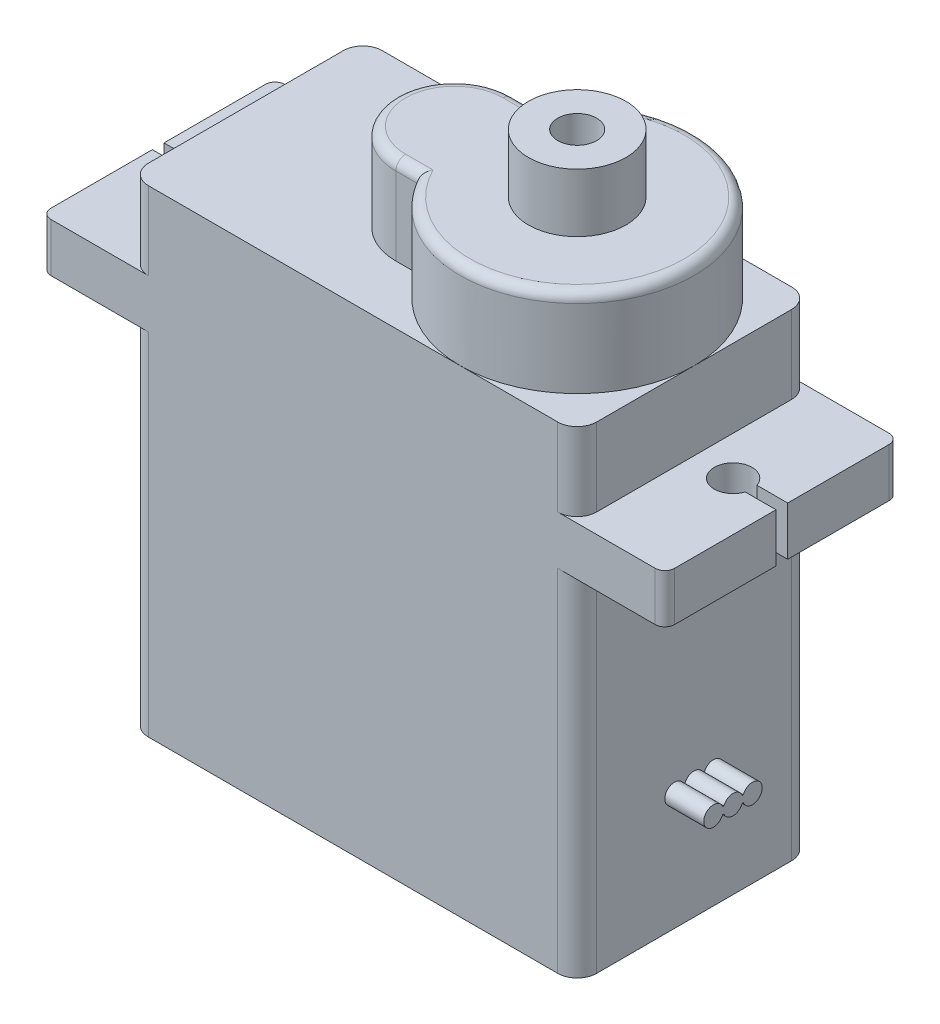
from build123d import *

# Parameters (mm, degrees)
SKETCH1_W            = 23
SKETCH1_H            = 12
BOSS_EXTRUDE1_DEPTH  = 18
SKETCH2_W            = 32
SKETCH2_H            = 12
BOSS_EXTRUDE2_DEPTH  = 2.5
SKETCH3_W            = 23
SKETCH3_H            = 12
BOSS_EXTRUDE3_DEPTH  = 4
BOSS_EXTRUDE4_DEPTH  = 4.5
FILLET1_R            = 1
FILLET2_R            = 0.5
CUT_EXTRUDE2_DEPTH   = 21.5
SKETCH5_R            = 2.5
BOSS_EXTRUDE5_DEPTH  = 3
SKETCH6_R            = 1
CUT_EXTRUDE1_DEPTH   = 3
BOSS_EXTRUDE11_DEPTH = 2
FILLET3_R            = 0.5


with BuildPart() as part:
    # Sketch1 → Boss-Extrude1 (new body)
    with BuildSketch(Plane(origin=(0, 0, 0), x_dir=(1, 0, 0), z_dir=(0, 1, 0))):
        Rectangle(SKETCH1_W, SKETCH1_H)
    extrude(amount=BOSS_EXTRUDE1_DEPTH)

    # Sketch2 → Boss-Extrude2 (add)
    with BuildSketch(Plane(origin=(0, 18, 0), x_dir=(1, 0, 0), z_dir=(0, 1, 0))):
        Rectangle(SKETCH2_W, SKETCH2_H)
    extrude(amount=BOSS_EXTRUDE2_DEPTH)

    # Sketch3 → Boss-Extrude3 (add)
    with BuildSketch(Plane(origin=(0, 20.5, 0), x_dir=(1, 0, 0), z_dir=(0, 1, 0))):
        Rectangle(SKETCH3_W, SKETCH3_H)
    extrude(amount=BOSS_EXTRUDE3_DEPTH)

    # Sketch4 → Boss-Extrude4 (add)
    with BuildSketch(Plane(origin=(0, 24.5, 0), x_dir=(1, 0, 0), z_dir=(0, 1, 0))):
        with BuildLine():
            Line((-0.802804538, 3), (0.303847577, 3))
            ThreePointArc((0.303847577, 3), (11.5, 0), (0.303847577, -3))
            Line((0.303847577, -3), (-0.802804538, -3))
            ThreePointArc((-0.802804538, -3), (-3.802804538, 0), (-0.802804538, 3))
        make_face()
    extrude(amount=BOSS_EXTRUDE4_DEPTH)

    # Fillet1
    fillet1_edges = [part.edges().sort_by_distance(p)[0] for p in [
        (11.5, 22.5, 6),
        (11.5, 22.5, -6),
        (-11.5, 22.5, -6),
        (-11.5, 22.5, 6),
        (11.5, 9, 6),
        (-11.5, 9, 6),
        (-11.5, 9, -6),
        (11.5, 9, -6),
    ]]
    fillet(fillet1_edges, radius=FILLET1_R)

    # Fillet2
    fillet2_edges = [part.edges().sort_by_distance(p)[0] for p in [
        (16, 19.25, 6),
        (16, 19.25, -6),
        (-16, 19.25, -6),
        (-16, 19.25, 6),
    ]]
    fillet(fillet2_edges, radius=FILLET2_R)

    # Sketch7 → Cut-Extrude2 (cut, through all)
    with BuildSketch(Plane(origin=(0, 20.5, 0), x_dir=(1, 0, 0), z_dir=(0, 1, 0))):
        with BuildLine():
            Line((14.420576737, 0.3), (16, 0.3))
            Line((16, 0.3), (16, -0.3))
            Line((16, -0.3), (14.420576737, -0.3))
            ThreePointArc((14.420576737, -0.3), (12.53177403, 0), (14.420576737, 0.3))
        make_face()
    cut_extrude2 = extrude(amount=-CUT_EXTRUDE2_DEPTH, mode=Mode.SUBTRACT)

    # Mirror1: Cut-Extrude2 across plane
    add(cut_extrude2.mirror(Plane(origin=(0, 0, 0), x_dir=(0, 0, 1), z_dir=(1, 0, 0))), mode=Mode.SUBTRACT)

    # Sketch5 → Boss-Extrude5 (add)
    with BuildSketch(Plane(origin=(0, 29, 0), x_dir=(1, 0, 0), z_dir=(0, 1, 0))):
        with Locations((5.5, 0)):
            Circle(SKETCH5_R)
    extrude(amount=BOSS_EXTRUDE5_DEPTH)

    # Sketch6 → Cut-Extrude1 (cut)
    with BuildSketch(Plane(origin=(0, 32, 0), x_dir=(1, 0, 0), z_dir=(0, 1, 0))):
        with Locations((5.5, 0)):
            Circle(SKETCH6_R)
    extrude(amount=-CUT_EXTRUDE1_DEPTH, mode=Mode.SUBTRACT)

    # Sketch8 → Boss-Extrude11 (add)
    with BuildSketch(Plane(origin=(11.5, 0, 0), x_dir=(0, 0, -1), z_dir=(1, 0, 0))):
        with BuildLine():
            Line((-0.539222972, 6.176789317), (-0.474627778, 6.176789317))
            ThreePointArc((-0.474627778, 6.176789317), (-0.006925375, 6.5), (0.460777028, 6.176789317))
            Line((0.460777028, 6.176789317), (0.525372222, 6.176789317))
            ThreePointArc((0.525372222, 6.176789317), (1.493074625, 6), (0.525372222, 5.823210683))
            Line((0.525372222, 5.823210683), (0.460777028, 5.823210683))
            ThreePointArc((0.460777028, 5.823210683), (-0.006925375, 5.5), (-0.474627778, 5.823210683))
            Line((-0.474627778, 5.823210683), (-0.539222972, 5.823210683))
            ThreePointArc((-0.539222972, 5.823210683), (-1.506925375, 6), (-0.539222972, 6.176789317))
        make_face()
    extrude(amount=BOSS_EXTRUDE11_DEPTH)

    # Fillet3
    fillet3_edges = [part.edges().sort_by_distance(p)[0] for p in [
        (-3.802804538, 29, 0),
        (-0.249478481, 29, 3),
        (11.5, 29, 0),
        (-0.249478481, 29, -3),
    ]]
    fillet(fillet3_edges, radius=FILLET3_R)


solid = part.part
